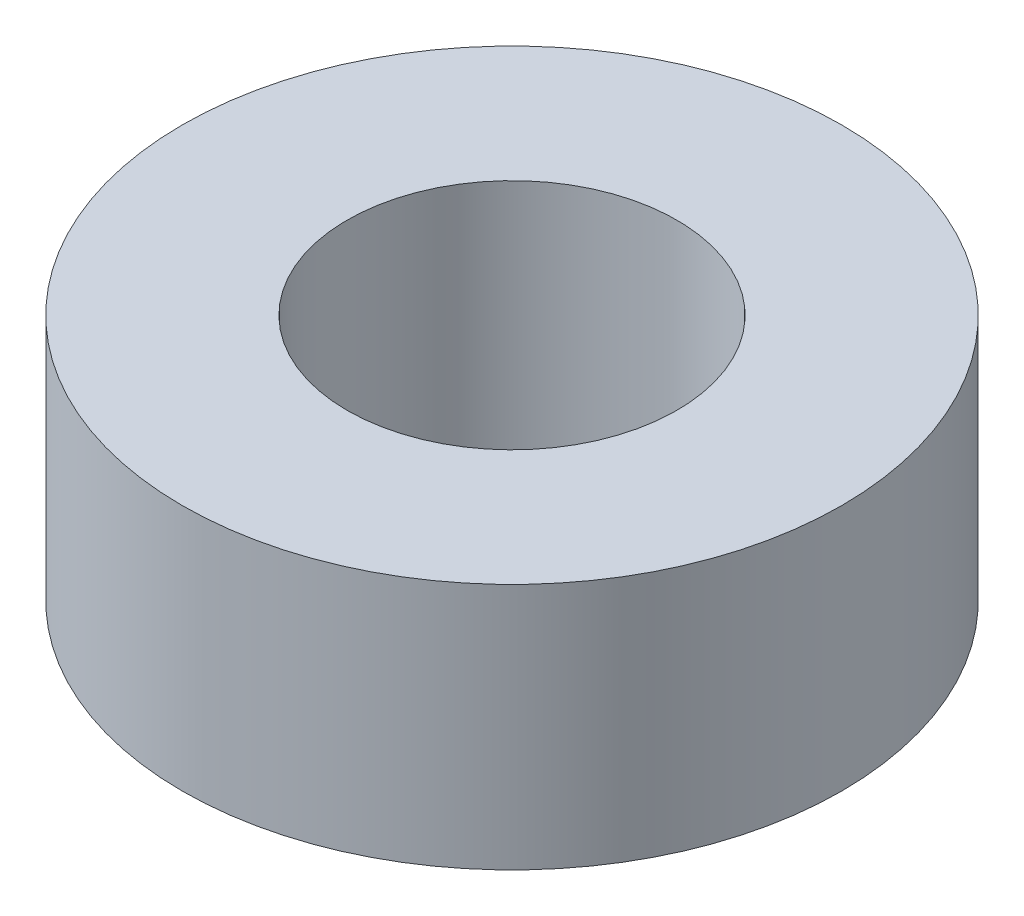
from build123d import *

# Parameters (mm, degrees)
SKETCH1_R           = 4
SKETCH1_R_2         = 2
BOSS_EXTRUDE1_DEPTH = 3


with BuildPart() as part:
    # Sketch1 → Boss-Extrude1 (new body)
    with BuildSketch(Plane(origin=(0, 0, 0), x_dir=(1, 0, 0), z_dir=(0, 1, 0))):
        Circle(SKETCH1_R)
        Circle(SKETCH1_R_2, mode=Mode.SUBTRACT)
    extrude(amount=BOSS_EXTRUDE1_DEPTH)


solid = part.part
